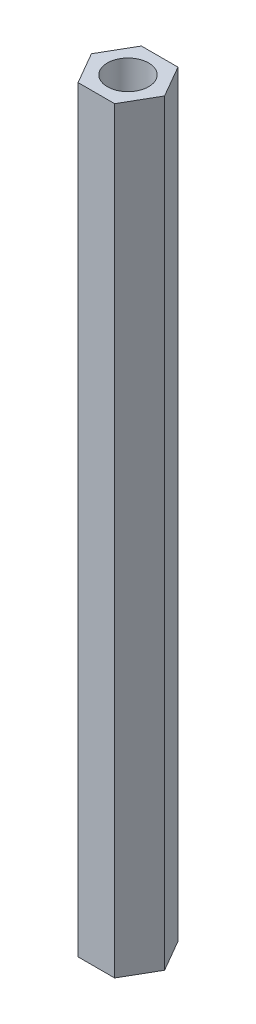
from build123d import *

# Parameters (mm, degrees)
BOSS_EXTRUDE1_DEPTH = 55
SKETCH2_R           = 1.5
CUT_EXTRUDE1_DEPTH  = 56


with BuildPart() as part:
    # Sketch1 → Boss-Extrude1 (new body)
    with BuildSketch(Plane(origin=(0, 0, 0), x_dir=(1, 0, 0), z_dir=(0, 1, 0))):
        Polygon((1.327905619, -2.3), (2.655811238, 0), (1.327905619, 2.3), (-1.327905619, 2.3), (-2.655811238, 0), (-1.327905619, -2.3), align=None)
    extrude(amount=BOSS_EXTRUDE1_DEPTH)

    # Sketch2 → Cut-Extrude1 (cut, through all)
    with BuildSketch(Plane(origin=(0, 55, 0), x_dir=(1, 0, 0), z_dir=(0, 1, 0))):
        Circle(SKETCH2_R)
    extrude(amount=-CUT_EXTRUDE1_DEPTH, mode=Mode.SUBTRACT)


solid = part.part
